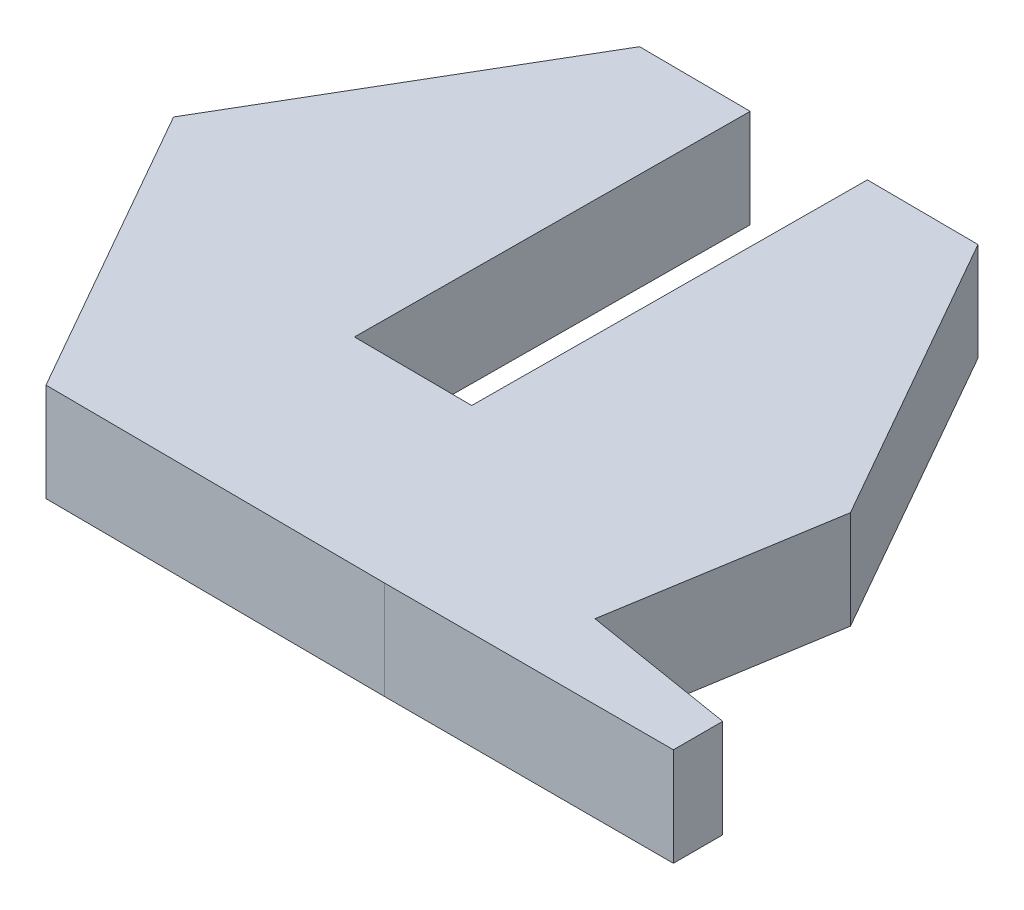
from build123d import *

# Parameters (mm, degrees)
BOSS_EXTRUDE1_DEPTH = 2.5
SKETCH2_W           = 3
SKETCH2_H           = 2.5
CUT_EXTRUDE1_DEPTH  = 10


with BuildPart() as part:
    # Sketch1 → Boss-Extrude1 (new body)
    with BuildSketch(Plane(origin=(0, 0, 0), x_dir=(1, 0, 0), z_dir=(0, 1, 0))):
        Polygon((12.694105225, -6.934131302), (12.694105225, -8.188855223), (5.34603962, -8.188855223), (-3.3140449, -8.134669239), (-7.59716072, -0.607723054), (-3.220192022, 6.865037146), (5.439892498, 6.810851162), (9.723008318, -0.716095023), (8.810324475, -6.299245302), align=None)
    extrude(amount=BOSS_EXTRUDE1_DEPTH)

    # Sketch2 → Cut-Extrude1 (cut)
    with BuildSketch(Plane(origin=(0.04282666, 0, -6.8446205), x_dir=(-0.999980426, 0, -0.006256859), z_dir=(0.006256859, 0, -0.999980426))):
        with Locations((-1.067171483, 1.25)):
            Rectangle(SKETCH2_W, SKETCH2_H)
    extrude(amount=-CUT_EXTRUDE1_DEPTH, mode=Mode.SUBTRACT)


solid = part.part
